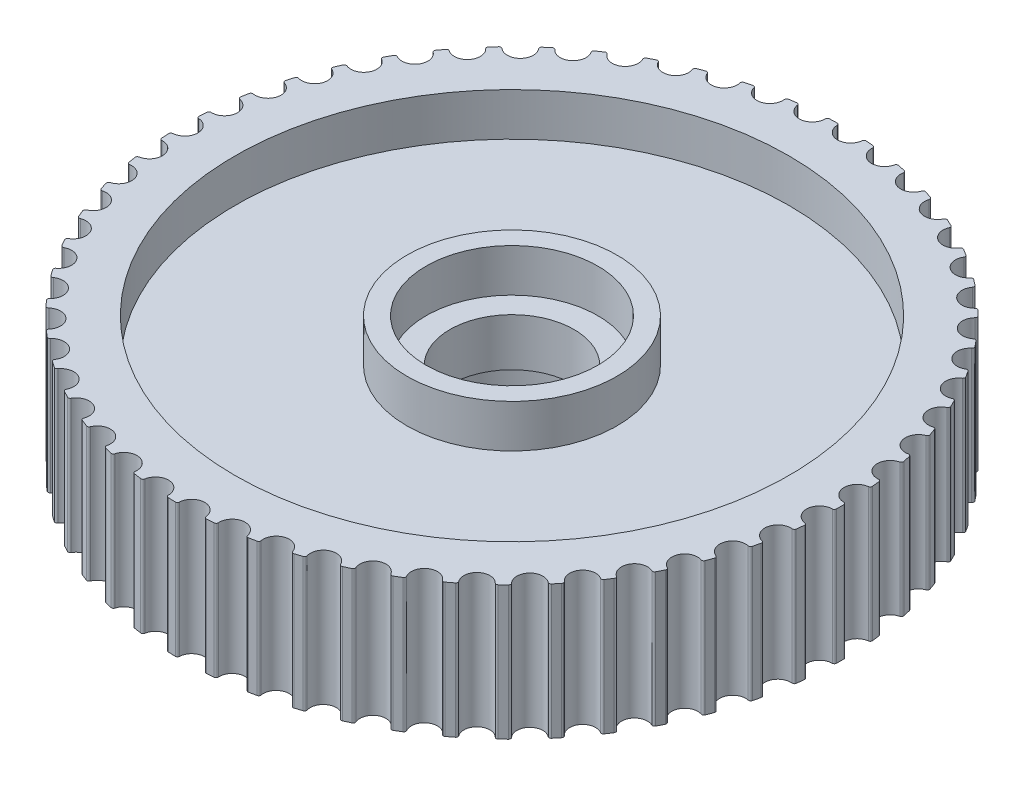
from build123d import *

# Parameters (mm, degrees)
SKETCH1_R           = 14.5
BOSS_EXTRUDE1_DEPTH = 3.5
SKETCH3_R           = 14.715478005
SKETCH3_R_2         = 5.5
SKETCH3_R_3         = 4.5
SKETCH3_R_4         = 3.25
BOSS_EXTRUDE2_DEPTH = 1.25
SKETCH3_3_R         = 5.5
SKETCH3_3_R_2       = 4.5
BOSS_EXTRUDE3_DEPTH = 3.5


with BuildPart() as part:
    # Sketch1 → Boss-Extrude1 (new, symmetric)
    with BuildSketch(Plane(origin=(0, 0, 0), x_dir=(1, 0, 0), z_dir=(0, 1, 0))):
        with BuildLine():
            Line((-2.578537229, 17.056190834), (-2.198350597, 17.109346997))
            ThreePointArc((-2.198350597, 17.109346997), (-2.117580993, 17.088751263), (-2.074443816, 17.017427375))
            ThreePointArc((-2.074443816, 17.017427375), (-1.347119033, 16.444916245), (-0.722655922, 17.128155703))
            ThreePointArc((-0.722655922, 17.128155703), (-0.692127967, 17.205104579), (-0.61659142, 17.238976623))
            Line((-0.61659142, 17.238976623), (-0.232823599, 17.24844829))
            ThreePointArc((-0.232823599, 17.24844829), (-0.15492821, 17.218779764), (-0.120202522, 17.143003516))
            ThreePointArc((-0.120202522, 17.143003516), (0.537120014, 16.491315388), (1.235396138, 17.09891788))
            ThreePointArc((1.235396138, 17.09891788), (1.274496615, 17.171885258), (1.353401917, 17.196925998))
            Line((1.353401917, 17.196925998), (1.735747926, 17.162589691))
            ThreePointArc((1.735747926, 17.162589691), (1.809753616, 17.124235147), (1.83561511, 17.044994398))
            ThreePointArc((1.83561511, 17.044994398), (2.414366196, 16.322625023), (3.177352237, 16.846669521))
            ThreePointArc((3.177352237, 16.846669521), (3.2245155, 16.91470416), (3.305760906, 16.930587151))
            Line((3.305760906, 16.930587151), (3.681700638, 16.852890497))
            ThreePointArc((3.681700638, 16.852890497), (3.750851851, 16.806349945), (3.767512009, 16.72467772))
            ThreePointArc((3.767512009, 16.72467772), (4.260146739, 15.941044288), (5.077896005, 16.374699071))
            ThreePointArc((5.077896005, 16.374699071), (5.13250721, 16.436914035), (5.215033562, 16.443432218))
            Line((5.215033562, 16.443432218), (5.579666068, 16.323388111))
            ThreePointArc((5.579666068, 16.323388111), (5.643061311, 16.269268279), (5.650302942, 16.1862293))
            ThreePointArc((5.650302942, 16.1862293), (6.050399069, 15.351547671), (6.912250949, 15.689159385))
            ThreePointArc((6.912250949, 15.689159385), (6.973598155, 15.744743607), (7.056329595, 15.741812008))
            Line((7.056329595, 15.741812008), (7.404901334, 15.580985407))
            ThreePointArc((7.404901334, 15.580985407), (7.461714154, 15.519991829), (7.459442851, 15.436668637))
            ThreePointArc((7.459442851, 15.436668637), (7.76178451, 14.561820161), (8.656503447, 14.798987522))
            ThreePointArc((8.656503447, 14.798987522), (8.723786899, 14.847216377), (8.805644897, 14.834873214))
            Line((8.805644897, 14.834873214), (9.133611701, 14.635360738))
            ThreePointArc((9.133611701, 14.635360738), (9.183101457, 14.568288559), (9.171346831, 14.485767399))
            ThreePointArc((9.171346831, 14.485767399), (9.371992535, 13.582157065), (10.287914499, 13.715788233))
            ThreePointArc((10.287914499, 13.715788233), (10.360257056, 13.756032984), (10.440174467, 13.734439168))
            Line((10.440174467, 13.734439168), (10.743260788, 13.49884177))
            ThreePointArc((10.743260788, 13.49884177), (10.784782304, 13.426565378), (10.763697595, 13.345922038))
            ThreePointArc((10.763697595, 13.345922038), (10.860031621, 12.425329789), (11.785216169, 12.453682678))
            ThreePointArc((11.785216169, 12.453682678), (11.861674733, 12.485418673), (11.938609712, 12.454855713))
            Line((11.938609712, 12.454855713), (12.212864357, 12.186244764))
            ThreePointArc((12.212864357, 12.186244764), (12.245876337, 12.109706392), (12.215736415, 12.031992183))
            ThreePointArc((12.215736415, 12.031992183), (12.206502902, 11.106419347), (13.128888838, 11.029124333))
            ThreePointArc((13.128888838, 11.029124333), (13.208466656, 11.051937845), (13.281416237, 11.012804175))
            Line((13.281416237, 11.012804175), (13.523263877, 10.71468143))
            ThreePointArc((13.523263877, 10.71468143), (13.547335959, 10.634878873), (13.508533745, 10.561106918))
            ThreePointArc((13.508533745, 10.561106918), (13.393853067, 9.642619752), (14.301415679, 9.460684494))
            ThreePointArc((14.301415679, 9.460684494), (14.383075332, 9.474278114), (14.451088507, 9.427083902))
            Line((14.451088507, 9.427083902), (14.657376287, 9.103335846))
            ThreePointArc((14.657376287, 9.103335846), (14.672194655, 9.021309453), (14.625235995, 8.952441482))
            ThreePointArc((14.625235995, 8.952441482), (14.406603189, 8.05301387), (15.287511011, 7.768810173))
            ThreePointArc((15.287511011, 7.768810173), (15.370187941, 7.773006687), (15.432378053, 7.718367182))
            Line((15.432378053, 7.718367182), (15.600416698, 7.373214367))
            ThreePointArc((15.600416698, 7.373214367), (15.605788171, 7.290033477), (15.551285244, 7.22696729))
            ThreePointArc((15.551285244, 7.22696729), (15.231550522, 6.358324647), (16.074319574, 5.97555754))
            ThreePointArc((16.074319574, 5.97555754), (16.15693596, 5.97030224), (16.212492266, 5.908929751))
            Line((16.212492266, 5.908929751), (16.340091135, 5.546871771))
            ThreePointArc((16.340091135, 5.546871771), (16.335945689, 5.463620774), (16.274609022, 5.407178535))
            ThreePointArc((16.274609022, 5.407178535), (15.857940616, 4.580644946), (16.651584114, 4.104304384))
            ThreePointArc((16.651584114, 4.104304384), (16.733062926, 4.089665781), (16.781261164, 4.022360393))
            Line((16.781261164, 4.022360393), (16.86675681, 3.648117228))
            ThreePointArc((16.86675681, 3.648117228), (16.853148487, 3.565881428), (16.785777698, 3.516798947))
            ThreePointArc((16.785777698, 3.516798947), (16.277607518, 2.743149543), (17.011779106, 2.179445353))
            ThreePointArc((17.011779106, 2.179445353), (17.091058142, 2.155614284), (17.131269976, 2.083253425))
            Line((17.131269976, 2.083253425), (17.173547832, 1.701703906))
            ThreePointArc((17.173547832, 1.701703906), (17.150654037, 1.621555374), (17.078127407, 1.580472516))
            ThreePointArc((17.078127407, 1.580472516), (16.485080229, 0.869792999), (17.150208856, 0.226073928))
            ThreePointArc((17.150208856, 0.226073928), (17.226254594, 0.193361067), (17.2579558, 0.116888071))
            Line((17.2579558, 0.116888071), (17.25646471, -0.266993719))
            ThreePointArc((17.25646471, -0.266993719), (17.224583899, -0.344010126), (17.147846924, -0.376557782))
            ThreePointArc((17.147846924, -0.376557782), (16.477654024, -1.015002619), (17.065068722, -1.730344708))
            ThreePointArc((17.065068722, -1.730344708), (17.136889788, -1.771512899), (17.159667093, -1.851101088))
            Line((17.159667093, -1.851101088), (17.114426496, -2.232310664))
            ThreePointArc((17.114426496, -2.232310664), (17.073974283, -2.30519092), (16.994027348, -2.328779065))
            ThreePointArc((16.994027348, -2.328779065), (16.255425715, -2.886666116), (16.757468636, -3.664305646))
            ThreePointArc((16.757468636, -3.664305646), (16.824128733, -3.713392476), (16.837685199, -3.795058305))
            Line((16.837685199, -3.795058305), (16.749284876, -4.168626017))
            ThreePointArc((16.749284876, -4.168626017), (16.700788618, -4.236420015), (16.618673951, -4.250741143))
            ThreePointArc((16.618673951, -4.250741143), (15.821292388, -4.720797496), (16.231418634, -5.550596747))
            ThreePointArc((16.231418634, -5.550596747), (16.292048746, -5.606962294), (16.296207644, -5.689641125))
            Line((16.296207644, -5.689641125), (16.165800028, -6.050696946))
            ThreePointArc((16.165800028, -6.050696946), (16.109891948, -6.112520888), (16.026680041, -6.1173883))
            ThreePointArc((16.026680041, -6.1173883), (15.180913635, -6.493486053), (15.493776583, -7.364627322))
            ThreePointArc((15.493776583, -7.364627322), (15.547586304, -7.427536776), (15.542293417, -7.510150762))
            Line((15.542293417, -7.510150762), (15.371578569, -7.853987778))
            ThreePointArc((15.371578569, -7.853987778), (15.308987515, -7.909035694), (15.225763162, -7.904385937))
            ThreePointArc((15.225763162, -7.904385937), (14.342637772, -8.18162208), (14.554158775, -9.082748708))
            ThreePointArc((14.554158775, -9.082748708), (14.600446613, -9.151381947), (14.585770942, -9.232854091))
            Line((14.585770942, -9.232854091), (14.376974392, -9.554989859))
            ThreePointArc((14.376974392, -9.554989859), (14.308516334, -9.602544116), (14.226364492, -9.588437805))
            ThreePointArc((14.226364492, -9.588437805), (13.317393008, -9.763198142), (13.424814566, -10.682562565))
            ThreePointArc((13.424814566, -10.682562565), (13.462977088, -10.756024851), (13.439109952, -10.835293037))
            Line((13.439109952, -10.835293037), (13.194953683, -11.131528027))
            ThreePointArc((13.194953683, -11.131528027), (13.121521075, -11.170968681), (13.041512719, -11.147589715))
            ThreePointArc((13.041512719, -11.147589715), (12.118544975, -11.217595977), (12.120466684, -12.143212874))
            ThreePointArc((12.120466684, -12.143212874), (12.150006383, -12.220546513), (12.117258927, -12.296577359))
            Line((12.117258927, -12.296577359), (11.84092589, -12.563049694))
            ThreePointArc((11.84092589, -12.563049694), (11.763476039, -12.593862577), (11.6866542, -12.561515736))
            ThreePointArc((11.6866542, -12.561515736), (10.761722491, -12.525855284), (10.658119299, -13.445657823))
            ThreePointArc((10.658119299, -13.445657823), (10.678651079, -13.525854653), (10.637450217, -13.597656982))
            Line((10.637450217, -13.597656982), (10.332542834, -13.830892786))
            ThreePointArc((10.332542834, -13.830892786), (10.252085418, -13.852676205), (10.179451586, -13.81178318))
            ThreePointArc((10.179451586, -13.81178318), (9.264613812, -13.670920902), (9.056836345, -14.572918052))
            ThreePointArc((9.056836345, -14.572918052), (9.068092544, -14.654932584), (9.018975391, -14.721570341))
            Line((9.018975391, -14.721570341), (8.689468597, -14.918529031))
            ThreePointArc((8.689468597, -14.918529031), (8.607052501, -14.930999006), (8.539553569, -14.882092899))
            ThreePointArc((8.539553569, -14.882092899), (7.64673604, -14.637865151), (7.337492994, -15.510297998))
            ThreePointArc((7.337492994, -15.510297998), (7.33932687, -15.593061048), (7.282933744, -15.653665509))
            Line((7.282933744, -15.653665509), (6.933123164, -15.811779426))
            ThreePointArc((6.933123164, -15.811779426), (6.849822808, -15.814773391), (6.788338728, -15.758491769))
            ThreePointArc((6.788338728, -15.758491769), (5.929180685, -15.414082433), (5.522503517, -16.245577481))
            ThreePointArc((5.522503517, -16.245577481), (5.514891163, -16.328010106), (5.451957234, -16.381791199))
            Line((5.451957234, -16.381791199), (5.086403183, -16.498999086))
            ThreePointArc((5.086403183, -16.498999086), (5.003304515, -16.492478011), (4.948636825, -16.42955459))
            ThreePointArc((4.948636825, -16.42955459), (4.134338707, -15.989453569), (3.635529076, -16.769171009))
            ThreePointArc((3.635529076, -16.769171009), (3.61856973, -16.850198572), (3.549915439, -16.896455179))
            Line((3.549915439, -16.896455179), (3.173383474, -16.971229053))
            ThreePointArc((3.173383474, -16.971229053), (3.091569811, -16.955277949), (3.04443119, -16.886533033))
            ThreePointArc((3.04443119, -16.886533033), (2.285608618, -16.356477716), (1.70116927, -17.074252738))
            ThreePointArc((1.70116927, -17.074252738), (1.675084023, -17.152818923), (1.601604383, -17.190948017))
            Line((1.601604383, -17.190948017), (1.219003174, -17.222313085))
            ThreePointArc((1.219003174, -17.222313085), (1.139541083, -17.197139901), (1.100546053, -17.123469684))
            ThreePointArc((1.100546053, -17.123469684), (0.407091441, -16.510370154), (-0.255358563, -17.156845462))
            ThreePointArc((-0.255358563, -17.156845462), (-0.29022965, -17.231926038), (-0.36757672, -17.261430549))
            Line((-0.36757672, -17.261430549), (-0.751259381, -17.24897792))
            ThreePointArc((-0.751259381, -17.24897792), (-0.827333991, -17.214910825), (-0.857677068, -17.137275712))
            ThreePointArc((-0.857677068, -17.137275712), (-1.47672348, -16.449124658), (-2.208548092, -17.015872459))
            ThreePointArc((-2.208548092, -17.015872459), (-2.25175042, -17.086488635), (-2.331956582, -17.106983927))
            Line((-2.331956582, -17.106983927), (-2.711718806, -17.05087594))
            ThreePointArc((-2.711718806, -17.05087594), (-2.783414184, -17.008359051), (-2.804709742, -16.927771134))
            ThreePointArc((-2.804709742, -16.927771134), (-3.341277736, -16.173539657), (-4.132936503, -16.653171527))
            ThreePointArc((-4.132936503, -16.653171527), (-4.183906864, -16.718402714), (-4.265926509, -16.729621598))
            Line((-4.265926509, -16.729621598), (-4.636817513, -16.630589707))
            ThreePointArc((-4.636817513, -16.630589707), (-4.703199002, -16.580177297), (-4.715169419, -16.497687163))
            ThreePointArc((-4.715169419, -16.497687163), (-5.162264012, -15.687207824), (-6.00343645, -16.073471028))
            ThreePointArc((-6.00343645, -16.073471028), (-6.061510368, -16.132466837), (-6.144274243, -16.134263059))
            Line((-6.144274243, -16.134263059), (-6.501458897, -15.993598295))
            ThreePointArc((-6.501458897, -15.993598295), (-6.561661112, -15.935947567), (-6.564150336, -15.852630601))
            ThreePointArc((-6.564150336, -15.852630601), (-6.915942965, -14.996469238), (-7.795663106, -15.284328244))
            ThreePointArc((-7.795663106, -15.284328244), (-7.860083498, -15.336319575), (-7.942512651, -15.328669717))
            Line((-7.942512651, -15.328669717), (-8.281334505, -15.148205861))
            ThreePointArc((-8.281334505, -15.148205861), (-8.334572619, -15.084068381), (-8.327548199, -15.001010746))
            ThreePointArc((-8.327548199, -15.001010746), (-8.57945271, -14.110328732), (-9.486252056, -14.296030857))
            ThreePointArc((-9.486252056, -14.296030857), (-9.556179104, -14.340339924), (-9.637198944, -14.323343715))
            Line((-9.637198944, -14.323343715), (-9.953240938, -14.105433389))
            ThreePointArc((-9.953240938, -14.105433389), (-9.99882091, -14.035645286), (-9.98237442, -13.953929767))
            ThreePointArc((-9.98237442, -13.953929767), (-10.131106852, -13.040338503), (-11.053163887, -13.121462837))
            ThreePointArc((-11.053163887, -13.121462837), (-11.127685986, -13.157512003), (-11.206240294, -13.131391014))
            Line((-11.206240294, -13.131391014), (-11.495382338, -12.878875013))
            ThreePointArc((-11.495382338, -12.878875013), (-11.532709964, -12.804346082), (-11.507055809, -12.725037964))
            ThreePointArc((-11.507055809, -12.725037964), (-11.550677208, -11.800447511), (-12.475971508, -11.775936473))
            ThreePointArc((-12.475971508, -11.775936473), (-12.554117147, -11.803255782), (-12.629181849, -11.76835054))
            Line((-12.629181849, -11.76835054), (-12.887654534, -11.484520796))
            ThreePointArc((-12.887654534, -11.484520796), (-12.91624319, -11.406222636), (-12.881715812, -11.330355823))
            ThreePointArc((-12.881715812, -11.330355823), (-12.819657505, -10.40681963), (-13.736126445, -10.27699276))
            ThreePointArc((-13.736126445, -10.27699276), (-13.816876876, -10.295226062), (-13.88747339, -10.251991611))
            Line((-13.88747339, -10.251991611), (-14.111907128, -9.940548278))
            ThreePointArc((-14.111907128, -9.940548278), (-14.131384118, -9.859501625), (-14.088433633, -9.788065156))
            ThreePointArc((-14.088433633, -9.788065156), (-13.921504647, -8.87762293), (-14.817200651, -8.64417272))
            ThreePointArc((-14.817200651, -8.64417272), (-14.89950317, -8.653082317), (-14.96471116, -8.602082284))
            Line((-14.96471116, -8.602082284), (-15.152180116, -8.267085503))
            ThreePointArc((-15.152180116, -8.267085503), (-15.162291527, -8.184346923), (-15.111477861, -8.118272083))
            ThreePointArc((-15.111477861, -8.118272083), (-14.841854369, -7.232792831), (-15.705100671, -6.89876266))
            ThreePointArc((-15.705100671, -6.89876266), (-15.787882338, -6.898232403), (-15.846851719, -6.84013165))
            Line((-15.846851719, -6.84013165), (-15.994911947, -6.485948616))
            ThreePointArc((-15.994911947, -6.485948616), (-15.995525962, -6.402596735), (-15.937511549, -6.342744909))
            ThreePointArc((-15.937511549, -6.342744909), (-15.568708506, -5.493772207), (-16.388251371, -5.063516671))
            ThreePointArc((-16.388251371, -5.063516671), (-16.470432999, -5.05355347), (-16.522395016, -4.98910943))
            Line((-16.522395016, -4.98910943), (-16.629116325, -4.620357461))
            ThreePointArc((-16.629116325, -4.620357461), (-16.620224939, -4.537478897), (-16.555766086, -4.484630346))
            ThreePointArc((-16.555766086, -4.484630346), (-16.092591403, -3.683231852), (-16.857746835, -3.162359988))
            ThreePointArc((-16.857746835, -3.162359988), (-16.938257063, -3.143093731), (-16.98253431, -3.073146531))
            Line((-16.98253431, -3.073146531), (-17.046525425, -2.694632872))
            ThreePointArc((-17.046525425, -2.694632872), (-17.028244551, -2.613308074), (-16.958181576, -2.56815176))
            ThreePointArc((-16.958181576, -2.56815176), (-16.406673445, -1.824774928), (-17.107466473, -1.220077098))
            ThreePointArc((-17.107466473, -1.220077098), (-17.185255726, -1.191758949), (-17.221270983, -1.117220458))
            Line((-17.221270983, -1.117220458), (-17.24169768, -0.733879614))
            ThreePointArc((-17.24169768, -0.733879614), (-17.214265638, -0.655168775), (-17.13951192, -0.618293379))
            ThreePointArc((-17.13951192, -0.618293379), (-16.506860091, 0.057370737), (-17.134154807, 0.738011371))
            ThreePointArc((-17.134154807, 0.738011371), (-17.208208983, 0.775012242), (-17.235492736, 0.853170301))
            Line((-17.235492736, 0.853170301), (-17.212088723, 1.236340896))
            ThreePointArc((-17.212088723, 1.236340896), (-17.175863131, 1.31141166), (-17.097393199, 1.339525411))
            ThreePointArc((-17.097393199, 1.339525411), (-16.391845257, 1.938668495), (-16.937463914, 2.686378742))
            ThreePointArc((-16.937463914, 2.686378742), (-17.006817604, 2.731579972), (-17.025014167, 2.81233869))
            Line((-17.025014167, 2.81233869), (-16.958084551, 3.190343821))
            ThreePointArc((-16.958084551, 3.190343821), (-16.913537665, 3.260795847), (-16.832374495, 3.279781447))
            ThreePointArc((-16.832374495, 3.279781447), (-16.063128336, 3.794592753), (-16.519957961, 4.599625068))
            ThreePointArc((-16.519957961, 4.599625068), (-16.583707034, 4.652437388), (-16.592579186, 4.734743951))
            Line((-16.592579186, 4.734743951), (-16.482996498, 5.102655744))
            ThreePointArc((-16.482996498, 5.102655744), (-16.430709053, 5.167570583), (-16.347910731, 5.177180525))
            ThreePointArc((-16.347910731, 5.177180525), (-15.524994656, 5.600948701), (-15.887079776, 6.452808255))
            ThreePointArc((-15.887079776, 6.452808255), (-15.944393165, 6.512543177), (-15.943825244, 6.595324594))
            Line((-15.943825244, 6.595324594), (-15.793018061, 6.948346754))
            ThreePointArc((-15.793018061, 6.948346754), (-15.733671707, 7.006878142), (-15.650317635, 7.006987147))
            ThreePointArc((-15.650317635, 7.006987147), (-14.784459613, 7.334187726), (-15.047079895, 8.221769227))
            ThreePointArc((-15.047079895, 8.221769227), (-15.097210431, 8.287648015), (-15.087209842, 8.369825102))
            Line((-15.087209842, 8.369825102), (-14.897144167, 8.703355448))
            ThreePointArc((-14.897144167, 8.703355448), (-14.831512572, 8.754740337), (-14.748689398, 8.745346984))
            ThreePointArc((-14.748689398, 8.745346984), (-13.851177213, 8.971714406), (-14.010908999, 9.883446872))
            ThreePointArc((-14.010908999, 9.883446872), (-14.053203156, 9.954610695), (-14.033900271, 10.03511215))
            Line((-14.033900271, 10.03511215), (-13.8070539, 10.344802602))
            ThreePointArc((-13.8070539, 10.344802602), (-13.735992673, 10.388371113), (-13.654780124, 10.369597858))
            ThreePointArc((-13.654780124, 10.369597858), (-12.737314219, 10.492181077), (-12.792075162, 11.416178681))
            ThreePointArc((-12.792075162, 11.416178681), (-12.82598157, 11.491699811), (-12.797628033, 11.569476172))
            Line((-12.797628033, 11.569476172), (-12.536958254, 11.851289442))
            ThreePointArc((-12.536958254, 11.851289442), (-12.461393787, 11.886473593), (-12.382850594, 11.858565174))
            ThreePointArc((-12.382850594, 11.858565174), (-11.45739154, 11.875766131), (-11.406467747, 12.799983152))
            ThreePointArc((-11.406467747, 12.799983152), (-11.431544384, 12.878877054), (-11.394509825, 12.952914389))
            Line((-11.394509825, 12.952914389), (-11.10341487, 13.20317661))
            ThreePointArc((-11.10341487, 13.20317661), (-11.024332261, 13.229517721), (-10.949482352, 13.192837966))
            ThreePointArc((-10.949482352, 13.192837966), (-10.028094924, 13.104432421), (-9.872150265, 14.016820276))
            ThreePointArc((-9.872150265, 14.016820276), (-9.888070219, 14.098058447), (-9.842837441, 14.167391566))
            Line((-9.842837441, 14.167391566), (-9.525112176, 14.382840187))
            ThreePointArc((-9.525112176, 14.382840187), (-9.443542388, 14.399994862), (-9.373361548, 14.355021949))
            ThreePointArc((-9.373361548, 14.355021949), (-8.46805744, 14.162162403), (-8.209124891, 15.05082672))
            ThreePointArc((-8.209124891, 15.05082672), (-8.21568062, 15.133350098), (-8.162839302, 15.197075136))
            Line((-8.162839302, 15.197075136), (-7.822625762, 15.374901456))
            ThreePointArc((-7.822625762, 15.374901456), (-7.739632182, 15.382646056), (-7.675035325, 15.329966276))
            ThreePointArc((-7.675035325, 15.329966276), (-6.79761656, 15.035166948), (-6.439071704, 15.88852263))
            ThreePointArc((-6.439071704, 15.88852263), (-6.436177745, 15.971255395), (-6.376416754, 16.028541601))
            Line((-6.376416754, 16.028541601), (-6.018150143, 16.16642738))
            ThreePointArc((-6.018150143, 16.16642738), (-5.934814719, 16.164660944), (-5.876643964, 16.104961058))
            ThreePointArc((-5.876643964, 16.104961058), (-5.038549038, 15.712065108), (-4.585066055, 16.518987358))
            ThreePointArc((-4.585066055, 16.518987358), (-4.572760135, 16.600850962), (-4.506858546, 16.650951522))
            Line((-4.506858546, 16.650951522), (-4.135209417, 16.747099209))
            ThreePointArc((-4.135209417, 16.747099209), (-4.052618554, 16.735844764), (-4.001632246, 16.669903052))
            ThreePointArc((-4.001632246, 16.669903052), (-3.213787007, 16.184032479), (-2.671277742, 16.934001831))
            ThreePointArc((-2.671277742, 16.934001831), (-2.649720287, 17.013929058), (-2.578537229, 17.056190834))
        make_face()
        Circle(SKETCH1_R, mode=Mode.SUBTRACT)
    extrude(amount=BOSS_EXTRUDE1_DEPTH, both=True)

    # Sketch3 → Boss-Extrude2 (add, symmetric)
    # profile 1 of 2: a face of its own
    with BuildSketch(Plane(origin=(0, 0, 0), x_dir=(1, 0, 0), z_dir=(0, 1, 0))):
        Circle(SKETCH3_R)
        Circle(SKETCH3_R_2, mode=Mode.SUBTRACT)
    # profile 2 of 2: a face of its own
    with BuildSketch(Plane(origin=(0, 0, 0), x_dir=(1, 0, 0), z_dir=(0, 1, 0))):
        Circle(SKETCH3_R_3)
        Circle(SKETCH3_R_4, mode=Mode.SUBTRACT)
    extrude(amount=BOSS_EXTRUDE2_DEPTH, both=True)


with BuildPart() as boss_extrude2_piece_1:
    # of the separate pieces the step leaves, piece 1, a body of its own (boss_extrude2_pieces)
    add(part.part.solids().sort_by_distance((-9.486252056, -3.5, 14.296030857))[0])



with BuildPart() as boss_extrude2_piece_2:
    # of the separate pieces the step leaves, piece 2, a body of its own (boss_extrude2_pieces)
    add(part.part.solids().sort_by_distance((4.5, -1.25, 0))[0])


with BuildPart() as boss_extrude2_piece_1_1:
    add(boss_extrude2_piece_1.part)

    add(boss_extrude2_piece_2.part)  # Boss-Extrude3 merges Boss-Extrude2 piece 2
    # Sketch3_3 → Boss-Extrude3 (add, symmetric)
    with BuildSketch(Plane(origin=(0, 0, 0), x_dir=(1, 0, 0), z_dir=(0, 1, 0))):
        Circle(SKETCH3_3_R)
        Circle(SKETCH3_3_R_2, mode=Mode.SUBTRACT)
    extrude(amount=BOSS_EXTRUDE3_DEPTH, both=True)


solid = boss_extrude2_piece_1_1.part
